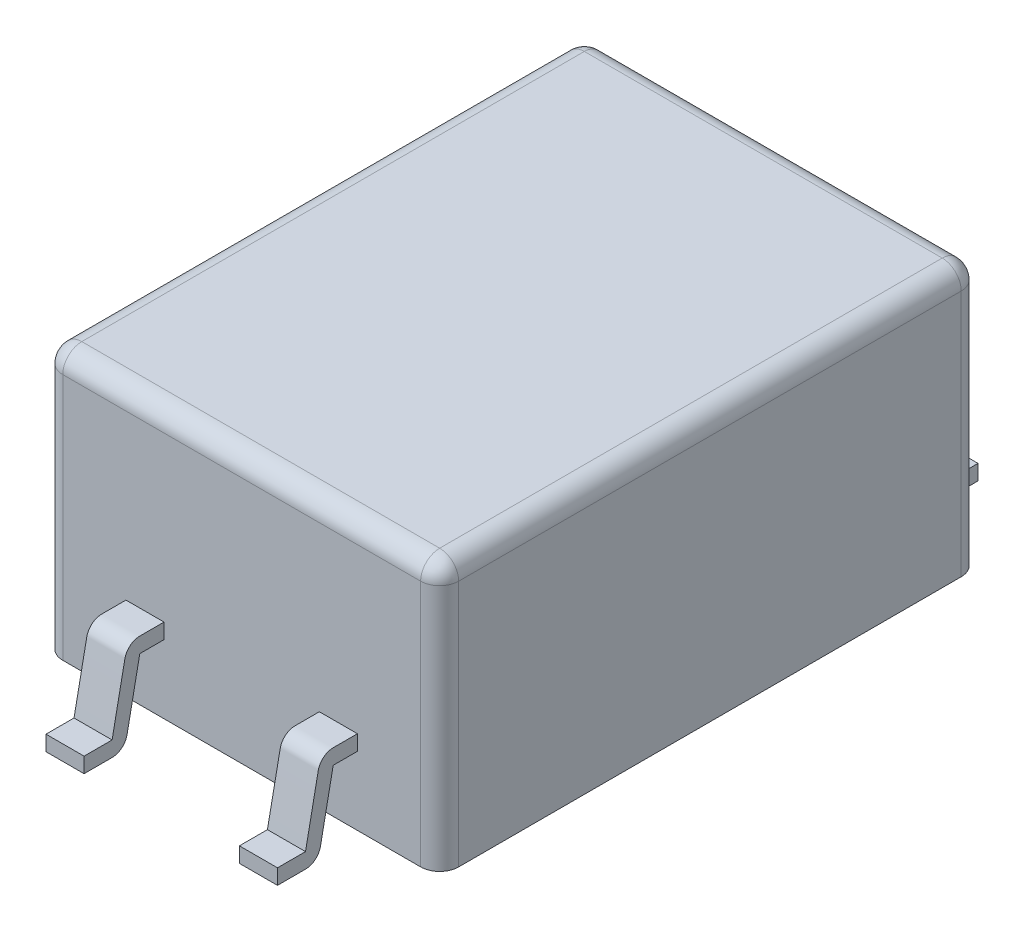
from build123d import *

# Parameters (mm, degrees)
EXTRUDE_1_DEPTH          = 3.5
FILLET_1_R               = 0.25
SKETCH_4_W               = 0.5
SKETCH_4_H               = 0.2
MIRROR_2_COPY_1_SKETCH_W = 0.5
MIRROR_2_COPY_1_SKETCH_H = 0.2


with BuildPart() as part:
    # Эскиз1 → Бобышка-Вытянуть1 (new body)
    with BuildSketch(Plane(origin=(0, 0, 0), x_dir=(1, 0, 0), z_dir=(0, 1, 0))):
        with BuildLine():
            Line((-2.35, -3.55), (2.35, -3.55))
            ThreePointArc((2.35, -3.55), (2.526776695, -3.476776695), (2.6, -3.3))
            Line((2.6, -3.3), (2.6, 3.3))
            ThreePointArc((2.6, 3.3), (2.526776695, 3.476776695), (2.35, 3.55))
            Line((2.35, 3.55), (-2.35, 3.55))
            ThreePointArc((-2.35, 3.55), (-2.526776695, 3.476776695), (-2.6, 3.3))
            Line((-2.6, 3.3), (-2.6, -3.3))
            ThreePointArc((-2.6, -3.3), (-2.526776695, -3.476776695), (-2.35, -3.55))
        make_face()
    extrude(amount=EXTRUDE_1_DEPTH)

    # Скругление1
    fillet_1_edges = [part.edges().sort_by_distance(p)[0] for p in [
        (2.526776695, 3.5, 3.476776695),
        (2.6, 3.5, 0),
        (2.526776695, 3.5, -3.476776695),
        (0, 3.5, -3.55),
        (-2.526776695, 3.5, -3.476776695),
        (-2.6, 3.5, 0),
        (-2.526776695, 3.5, 3.476776695),
        (0, 3.5, 3.55),
    ]]
    fillet(fillet_1_edges, radius=FILLET_1_R)

    # По траектории3: sweep along a path in Эскиз3
    with BuildLine(Plane(origin=(1.27, 0, 0), x_dir=(0, 0, -1), z_dir=(1, 0, 0))) as sweep_3_path:
        Line((-3.55, 1), (-3.86801961, 1))
        ThreePointArc((-3.86801961, 1), (-3.9314185, 0.977334214), (-3.966077677, 0.919611614))
        Line((-3.966077677, 0.919611614), (-4.133922323, 0.080388386))
        ThreePointArc((-4.133922323, 0.080388386), (-4.1685815, 0.022665786), (-4.23198039, 0))
        Line((-4.23198039, 0), (-4.6, 0))
    # Эскиз4 → По траектории3 (sweep)
    with BuildSketch(Plane.XY.offset(3.55)):
        with Locations((1.27, 1)):
            Rectangle(SKETCH_4_W, SKETCH_4_H)
    sweep_3 = sweep(path=sweep_3_path.line)

    # Зеркальное отражение1: По траектории3 across plane
    add(sweep_3.mirror(Plane.XY))

    # Зеркальное отражение2: По траектории3 across plane
    add(sweep_3.mirror(Plane(origin=(0, 0, 0), x_dir=(0, 0, 1), z_dir=(1, 0, 0))))

    # Зеркальное отражение2 copy 1: sweep along a path in Зеркальное отражение2 copy 1 path
    with BuildLine(Plane.ZY.offset(1.27)) as mirror_2_copy_1_path:
        Line((-3.55, 1), (-3.86801961, 1))
        ThreePointArc((-3.86801961, 1), (-3.9314185, 0.977334214), (-3.966077677, 0.919611614))
        Line((-3.966077677, 0.919611614), (-4.133922323, 0.080388386))
        ThreePointArc((-4.133922323, 0.080388386), (-4.1685815, 0.022665786), (-4.23198039, 0))
        Line((-4.23198039, 0), (-4.6, 0))
    # Зеркальное отражение2 copy 1 sketch → Зеркальное отражение2 copy 1 (sweep)
    with BuildSketch(Plane(origin=(0, 0, -3.55), x_dir=(-1, 0, 0), z_dir=(0, 0, -1))):
        with Locations((1.27, 1)):
            Rectangle(MIRROR_2_COPY_1_SKETCH_W, MIRROR_2_COPY_1_SKETCH_H)
    sweep(path=mirror_2_copy_1_path.line)


solid = part.part
